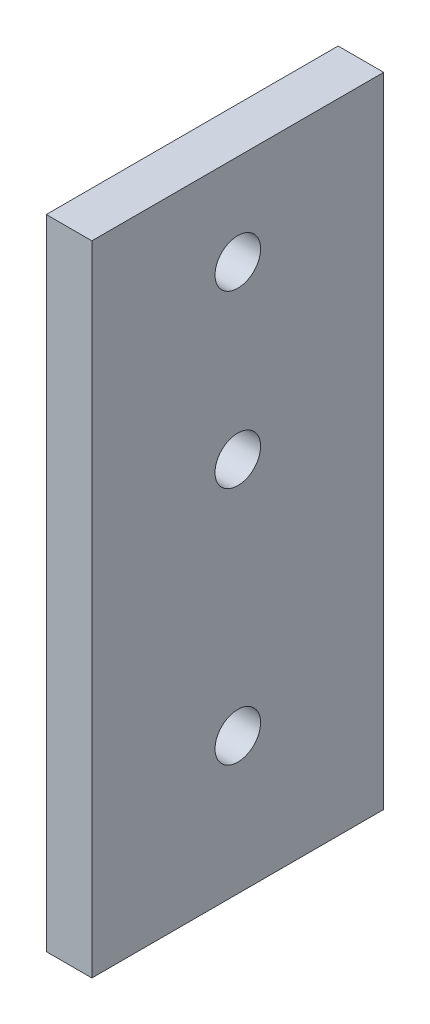
from build123d import *

# Parameters (mm, degrees)
SKETCH1_W           = 40.64
SKETCH1_H           = 88.9
BOSS_EXTRUDE1_DEPTH = 6.35
SKETCH3_R           = 3.175
CUT_EXTRUDE1_DEPTH  = 6.35


with BuildPart() as part:
    # Sketch1 → Boss-Extrude1 (new body)
    with BuildSketch(Plane(origin=(0, 0, 0), x_dir=(0, 0, -1), z_dir=(1, 0, 0))):
        with Locations((20.32, 44.45)):
            Rectangle(SKETCH1_W, SKETCH1_H)
    extrude(amount=BOSS_EXTRUDE1_DEPTH)

    # Sketch3 → Cut-Extrude1 (cut)
    with BuildSketch(Plane(origin=(6.35, 0, 0), x_dir=(0, 0, -1), z_dir=(1, 0, 0))):
        with Locations((20.32, 19.05)):
            Circle(SKETCH3_R)
        with Locations((20.32, 52.3875)):
            Circle(SKETCH3_R)
        with Locations((20.32, 76.2)):
            Circle(SKETCH3_R)
    extrude(amount=-CUT_EXTRUDE1_DEPTH, mode=Mode.SUBTRACT)


solid = part.part
